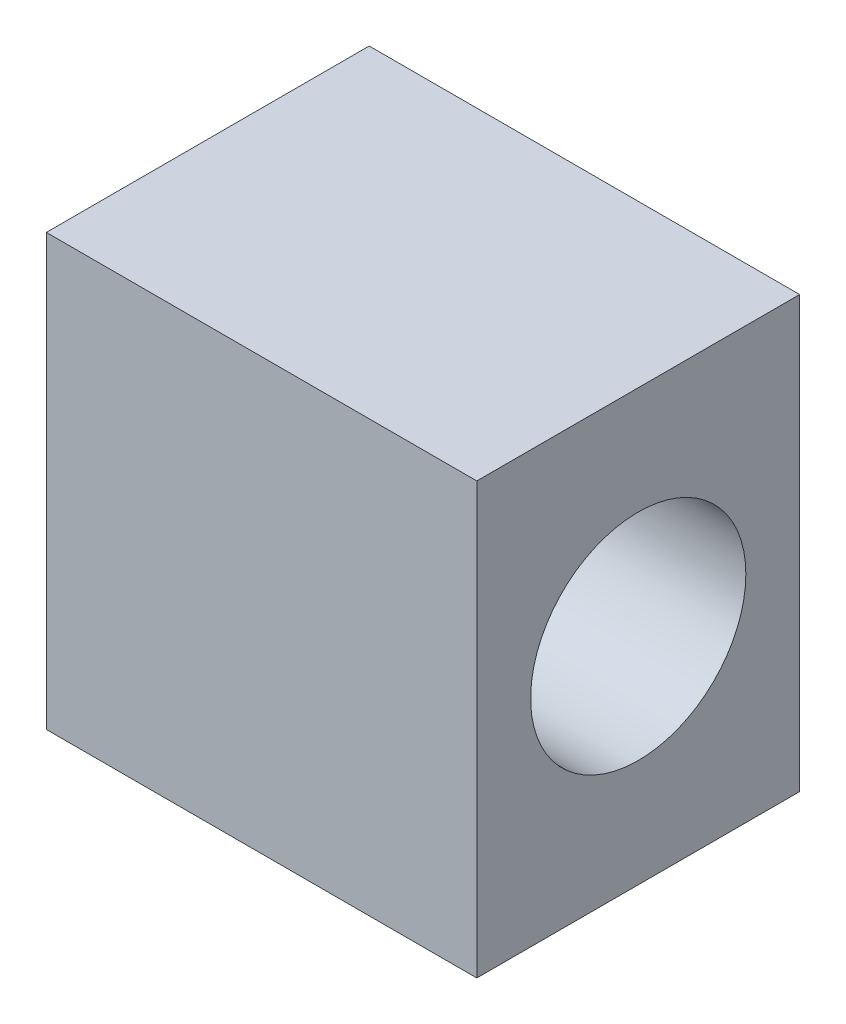
from build123d import *

# Parameters (mm, degrees)
SKETCH3_W           = 20
SKETCH3_H           = 15
BOSS_EXTRUDE1_DEPTH = 20
SKETCH5_R           = 5
CUT_EXTRUDE1_DEPTH  = 10


with BuildPart() as part:
    # Sketch3 → Boss-Extrude1 (new body)
    with BuildSketch(Plane(origin=(0, 0, 0), x_dir=(1, 0, 0), z_dir=(0, 1, 0))):
        Rectangle(SKETCH3_W, SKETCH3_H)
    extrude(amount=BOSS_EXTRUDE1_DEPTH)

    # Sketch5 → Cut-Extrude1 (cut)
    with BuildSketch(Plane(origin=(10, 0, 0), x_dir=(0, 0, -1), z_dir=(1, 0, 0))):
        with Locations((0, 10)):
            Circle(SKETCH5_R)
    extrude(amount=-CUT_EXTRUDE1_DEPTH, mode=Mode.SUBTRACT)


solid = part.part
